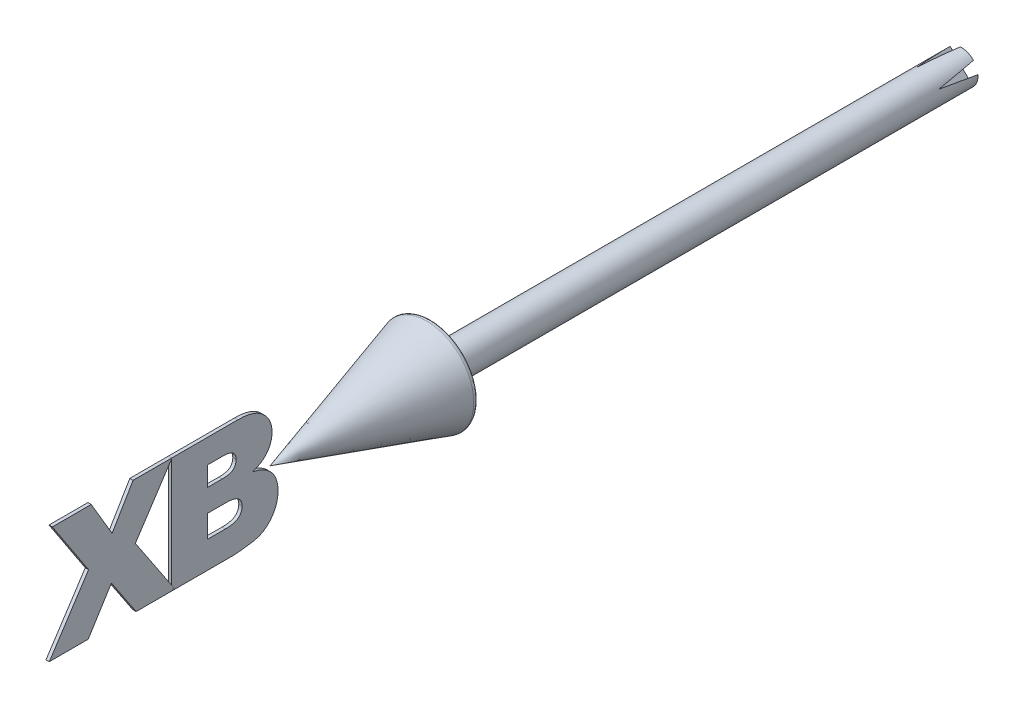
from build123d import *

# Parameters (mm, degrees)
FILLET1_R          = 1
EXTRUDE_X_DEPTH    = 0.5
EXTRUDE_B_DEPTH    = 0.5
CUT_EXTRUDE1_DEPTH = 269.84640065
CIRPATTERN1_COUNT  = 4


with BuildPart() as part:
    # Sketch1 → Revolve1 (revolve)
    with BuildSketch(Plane(origin=(0, 0, 0), x_dir=(0, 0, -1), z_dir=(1, 0, 0))):
        Polygon((-200, 0), (10, 0), (10, -5), (-155.773502692, -5), (-150, -15), align=None)
    revolve(axis=Axis((0, 0, 200), (0, 0, 1)))

    # Fillet1
    fillet1_edges = [part.edges().sort_by_distance(p)[0] for p in [
        (0, 15, 150),
    ]]
    fillet(fillet1_edges, radius=FILLET1_R)

    # Sketch26 → Cut-Extrude1 (cut, through all)
    with BuildSketch(Plane(origin=(-1.039304762, 1.039304762, -0.220911047), x_dir=(0.6666795016305326, 0.7129078853389496, 0.2174874459071417), z_dir=(0.6992527780868754, -0.6992527780868756, 0.14863076624835747))):
        Polygon((-10.88821277, -32.158941839), (-1.20382422, -34.342289942), (2.224725929, 1.720185122), align=None)
    cut_extrude1 = extrude(amount=-CUT_EXTRUDE1_DEPTH, mode=Mode.SUBTRACT)

    # CirPattern1: Cut-Extrude1 ×4 about axis
    cirpattern1_axis = Axis((0, 0, 281.422727273), (0, 0, -1))
    for i in range(1, CIRPATTERN1_COUNT):
        add(cut_extrude1.rotate(cirpattern1_axis, i * 360 / CIRPATTERN1_COUNT), mode=Mode.SUBTRACT)


with BuildPart() as body_2:
    # Sketch10 → Extrude X (new, symmetric)
    with BuildSketch(Plane(origin=(0, 0, 0), x_dir=(0, 0, -1), z_dir=(1, 0, 0))):
        Polygon((-266.636363636, 17.5), (-254.818181818, 17.5), (-248.46875, 6.732954545), (-242.090909091, 17.5), (-230.272727273, 17.5), (-241.394886364, 0.546875), (-229.363636364, -17.5), (-241.181818182, -17.5), (-248.681818182, -6.257102273), (-255.727272727, -17.5), (-267.545454545, -17.5), (-255.620738636, 0.738636364), align=None)
    extrude(amount=EXTRUDE_X_DEPTH, both=True)


with BuildPart() as body_3:
    # Sketch19 → Extrude B (new, symmetric)
    with BuildSketch(Plane(origin=(0, 0, 0), x_dir=(0, 0, -1), z_dir=(1, 0, 0))):
        with BuildLine():
            Line((-230.363636364, 17.5), (-210.299715909, 17.5))
            add(Edge.make_bspline(
                [(-210.299715909, 17.5), (-209.892231653, 17.494192787), (-209.101606157, 17.482925281), (-207.952462342, 17.36709121), (-206.875857126, 17.178354119), (-205.873219215, 16.908545289), (-204.941499597, 16.568504152), (-204.083579567, 16.148345137), (-203.298774092, 15.648779692), (-202.588537534, 15.080104807), (-201.958357944, 14.458181122), (-201.411765231, 13.790585358), (-200.952563, 13.085828588), (-200.559359843, 12.351260609), (-200.271363357, 11.573232318), (-200.064953199, 10.761330108), (-199.93227264, 9.914380049), (-199.916897626, 9.335248991), (-199.909090909, 9.041193182)],
                knots=[0, 0, 0, 0, 1.297654395, 2.517787213, 3.674586828, 4.77585146, 5.820915781, 6.829339549, 7.812606932, 8.77836667, 9.72223708, 10.627980282, 11.521109072, 12.398141818, 13.276373382, 14.156157737, 15.063782678, 16, 16, 16, 16], degree=3))
            add(Edge.make_bspline(
                [(-199.909090909, 9.041193182), (-199.913787405, 8.794669613), (-199.923034398, 8.309286146), (-200.019225659, 7.593686747), (-200.173260998, 6.903363024), (-200.396452204, 6.241310276), (-200.672642156, 5.604350414), (-201.016575624, 4.99836148), (-201.423385119, 4.417782047), (-201.737981586, 4.059678571), (-201.897727273, 3.877840909)],
                knots=[0, 0, 0, 0, 1.04282744, 2.053236539, 3.049839399, 4.032084381, 5.005705807, 5.983802495, 6.976215915, 8, 8, 8, 8], degree=3))
            add(Edge.make_bspline(
                [(-201.897727273, 3.877840909), (-202.136953354, 3.642120471), (-202.633078049, 3.153266038), (-203.550736429, 2.55869324), (-204.603828774, 2.020541444), (-205.37869969, 1.747474304), (-205.782670455, 1.605113636)],
                knots=[0, 0, 0, 0, 0.884375131, 1.834082386, 2.870821738, 4, 4, 4, 4], degree=3))
            add(Edge.make_bspline(
                [(-205.782670455, 1.605113636), (-205.462142917, 1.523322784), (-204.839819944, 1.364521058), (-203.944803235, 1.075381646), (-203.120709218, 0.728843274), (-202.352431548, 0.361252264), (-201.657010697, -0.065249565), (-201.02277228, -0.525459582), (-200.450358303, -1.028751844), (-199.953517441, -1.582596127), (-199.506475797, -2.164961258), (-199.134251389, -2.793319892), (-198.808892883, -3.451798919), (-198.547906179, -4.149583939), (-198.341962453, -4.883802139), (-198.191749339, -5.652991068), (-198.10694181, -6.458771941), (-198.096321054, -7.007380301), (-198.090909091, -7.286931818)],
                knots=[0, 0, 0, 0, 1.232819589, 2.393591379, 3.501302721, 4.562821732, 5.564607723, 6.537052917, 7.480854037, 8.39906542, 9.306143972, 10.212578551, 11.116260356, 12.040556594, 12.984728859, 13.955531373, 14.958210724, 16, 16, 16, 16], degree=3))
            add(Edge.make_bspline(
                [(-198.090909091, -7.286931818), (-198.105207496, -7.742523492), (-198.133184892, -8.633970438), (-198.37432871, -9.936142868), (-198.772918528, -11.166201905), (-199.329753977, -12.317067128), (-200.016068797, -13.375591902), (-200.828273913, -14.322768344), (-201.753408126, -15.158965892), (-202.454235469, -15.606043441), (-202.806818182, -15.830965909)],
                knots=[0, 0, 0, 0, 1.069033233, 2.091755547, 3.097262418, 4.096727932, 5.085032136, 6.050930718, 7.019433042, 8, 8, 8, 8], degree=3))
            add(Edge.make_bspline(
                [(-202.806818182, -15.830965909), (-203.059431495, -15.963560484), (-203.604881567, -16.249862577), (-204.556924834, -16.551964276), (-205.668707387, -16.826305999), (-206.474895073, -16.946072508), (-206.904829545, -17.009943182)],
                knots=[0, 0, 0, 0, 0.796985197, 1.720873805, 2.784557324, 4, 4, 4, 4], degree=3))
            add(Edge.make_bspline(
                [(-206.904829545, -17.009943182), (-207.195985354, -17.048104595), (-207.752089637, -17.120992461), (-208.547527756, -17.220751829), (-209.267253243, -17.305635962), (-209.908313312, -17.380118071), (-210.475026537, -17.425168768), (-210.964295475, -17.473559182), (-211.379075066, -17.494055383), (-211.63019682, -17.498174626), (-211.741477273, -17.5)],
                knots=[0, 0, 0, 0, 1.448973724, 2.76752333, 3.95568902, 5.025137038, 5.951619243, 6.760708843, 7.450828619, 8, 8, 8, 8], degree=3))
            Line((-211.741477273, -17.5), (-230.363636364, -17.5))
            Line((-230.363636364, -17.5), (-230.363636364, 17.5))
        make_face()
        with BuildLine():
            Line((-219.454545455, 4.318181818), (-215.044034091, 4.318181818))
            add(Edge.make_bspline(
                [(-215.044034091, 4.318181818), (-214.854574176, 4.321176961), (-214.489519117, 4.32694806), (-213.963424272, 4.363262572), (-213.481254173, 4.41634344), (-213.043593707, 4.500340425), (-212.655942948, 4.615780771), (-212.307908157, 4.74049072), (-212.006020725, 4.897083701), (-211.668961943, 5.141191918), (-211.323579797, 5.512092037), (-211.027459427, 6.045724496), (-210.844279349, 6.664432723), (-210.827149075, 7.105670904), (-210.818181818, 7.336647727)],
                knots=[0, 0, 0, 0, 1.145480684, 2.207134515, 3.187201839, 4.077092928, 4.897001117, 5.630796186, 6.309468702, 6.945115061, 8.140144207, 9.338597513, 10.606824343, 12, 12, 12, 12], degree=3))
            add(Edge.make_bspline(
                [(-210.818181818, 7.336647727), (-210.827262035, 7.553474867), (-210.844673426, 7.969242703), (-211.028645225, 8.553135019), (-211.32864811, 9.057556585), (-211.746281019, 9.494124438), (-212.322255504, 9.836294854), (-213.06177619, 10.067441536), (-213.966676378, 10.202692692), (-214.62447065, 10.218646918), (-214.980113636, 10.227272727)],
                knots=[0, 0, 0, 0, 0.898975673, 1.7237933, 2.513644222, 3.320957883, 4.208713874, 5.266782133, 6.522258696, 8, 8, 8, 8], degree=3))
            Line((-214.980113636, 10.227272727), (-219.454545455, 10.227272727))
            Line((-219.454545455, 10.227272727), (-219.454545455, 4.318181818))
        make_face(mode=Mode.SUBTRACT)
        with BuildLine():
            Line((-219.454545455, -9.318181818), (-214.014204545, -9.318181818))
            add(Edge.make_bspline(
                [(-214.014204545, -9.318181818), (-213.793982279, -9.315413505), (-213.367304023, -9.310049927), (-212.75263587, -9.270365199), (-212.188024307, -9.19212056), (-211.676632574, -9.083813698), (-211.212111462, -8.962759351), (-210.800423288, -8.796178425), (-210.440621741, -8.600116724), (-210.031719916, -8.306020566), (-209.614533345, -7.872216965), (-209.257719152, -7.25491433), (-209.035656219, -6.556035014), (-209.012180523, -6.059952557), (-209, -5.802556818)],
                knots=[0, 0, 0, 0, 1.137803444, 2.204481845, 3.180101913, 4.079687281, 4.904664318, 5.65648604, 6.368130755, 7.016521866, 8.253609545, 9.443098973, 10.673334608, 12, 12, 12, 12], degree=3))
            add(Edge.make_bspline(
                [(-209, -5.802556818), (-209.013141009, -5.564297885), (-209.038521686, -5.104122178), (-209.250782778, -4.447441583), (-209.619689188, -3.876704499), (-210.029506482, -3.464359909), (-210.431004909, -3.183783246), (-210.791655012, -2.998201063), (-211.204786197, -2.844766536), (-211.670577479, -2.71679488), (-212.188598422, -2.619815555), (-212.757899989, -2.550089555), (-213.379077775, -2.507205385), (-213.810532861, -2.502469491), (-214.035511364, -2.5)],
                knots=[0, 0, 0, 0, 1.255417871, 2.424726742, 3.592633522, 4.811599848, 5.466560168, 6.1705524, 6.945451491, 7.787981907, 8.716507248, 9.723634385, 10.813008945, 12, 12, 12, 12], degree=3))
            Line((-214.035511364, -2.5), (-219.454545455, -2.5))
            Line((-219.454545455, -2.5), (-219.454545455, -9.318181818))
        make_face(mode=Mode.SUBTRACT)
    extrude(amount=EXTRUDE_B_DEPTH, both=True)


solid = Compound([part.part, body_2.part, body_3.part])
